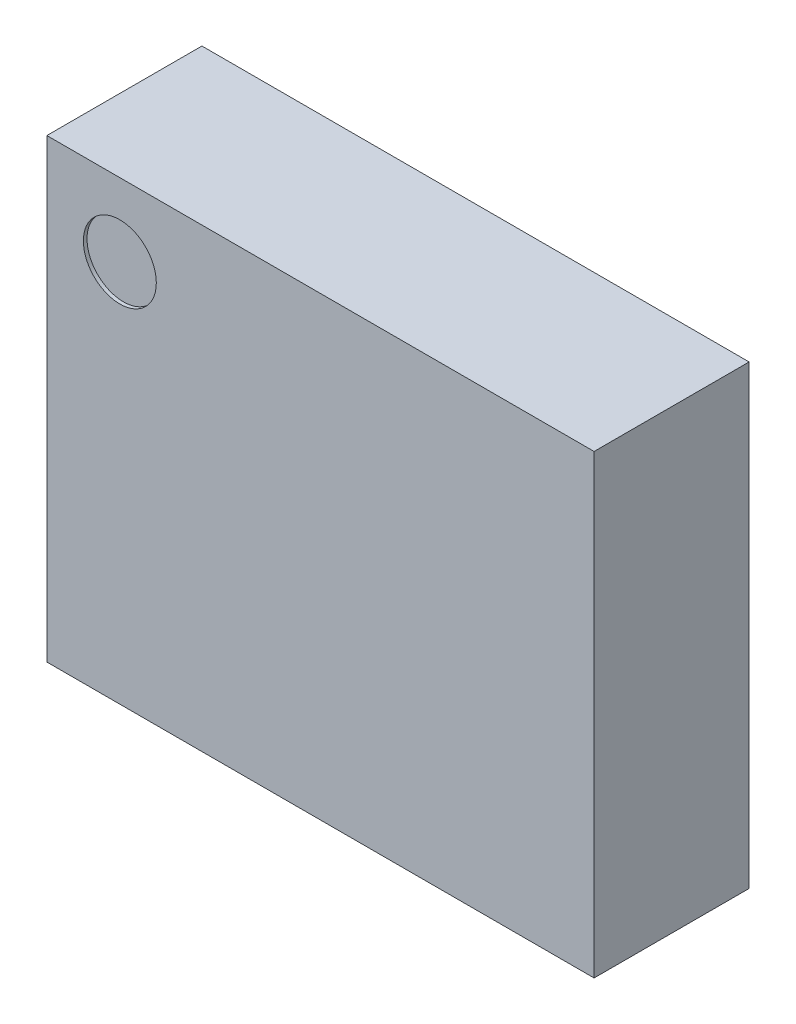
from build123d import *

# Parameters (mm, degrees)
SKETCH1_W           = 3
SKETCH1_H           = 2.5
BOSS_EXTRUDE1_DEPTH = 0.8
SKETCH2_R           = 0.2
CUT_EXTRUDE1_DEPTH  = 0.02
SKETCH3_W           = 0.25
SKETCH3_H           = 0.475
SKETCH3_W_2         = 0.475
SKETCH3_H_2         = 0.25
BOSS_EXTRUDE2_DEPTH = 0.1
SKETCH4_W           = 3
SKETCH4_H           = 2.5
BOSS_EXTRUDE3_DEPTH = 0.05


with BuildPart() as part:
    # Sketch1 → Boss-Extrude1 (new body)
    with BuildSketch(Plane.XY):
        Rectangle(SKETCH1_W, SKETCH1_H)
    extrude(amount=BOSS_EXTRUDE1_DEPTH)

    # Sketch2 → Cut-Extrude1 (cut)
    with BuildSketch(Plane.XY.offset(0.8)):
        with Locations((-1.1, 0.85)):
            Circle(SKETCH2_R)
    extrude(amount=-CUT_EXTRUDE1_DEPTH, mode=Mode.SUBTRACT)

    # Sketch3 → Boss-Extrude2 (add)
    with BuildSketch(Plane(origin=(0, 0, 0), x_dir=(-1, 0, 0), z_dir=(0, 0, -1))):
        with Locations((0.5, 0.9125)):
            Rectangle(SKETCH3_W, SKETCH3_H)
        with Locations((0, 0.9125)):
            Rectangle(SKETCH3_W, SKETCH3_H)
        with Locations((-0.5, 0.9125)):
            Rectangle(SKETCH3_W, SKETCH3_H)
        with Locations((0.5, -0.9125)):
            Rectangle(SKETCH3_W, SKETCH3_H)
        with Locations((0, -0.9125)):
            Rectangle(SKETCH3_W, SKETCH3_H)
        with Locations((-0.5, -0.9125)):
            Rectangle(SKETCH3_W, SKETCH3_H)
        with Locations((-1.1625, -0.25)):
            Rectangle(SKETCH3_W_2, SKETCH3_H_2)
        with Locations((-1.1625, 0.25)):
            Rectangle(SKETCH3_W_2, SKETCH3_H_2)
        with Locations((-1.1625, -0.75)):
            Rectangle(SKETCH3_W_2, SKETCH3_H_2)
        with Locations((-1.1625, 0.75)):
            Rectangle(SKETCH3_W_2, SKETCH3_H_2)
        with Locations((1.1625, -0.75)):
            Rectangle(SKETCH3_W_2, SKETCH3_H_2)
        with Locations((1.1625, -0.25)):
            Rectangle(SKETCH3_W_2, SKETCH3_H_2)
        with Locations((1.1625, 0.25)):
            Rectangle(SKETCH3_W_2, SKETCH3_H_2)
        with Locations((1.1625, 0.75)):
            Rectangle(SKETCH3_W_2, SKETCH3_H_2)
    extrude(amount=BOSS_EXTRUDE2_DEPTH)

    # Sketch4 → Boss-Extrude3 (add)
    with BuildSketch(Plane(origin=(0, 0, 0), x_dir=(-1, 0, 0), z_dir=(0, 0, -1))):
        Rectangle(SKETCH4_W, SKETCH4_H)
    extrude(amount=BOSS_EXTRUDE3_DEPTH)


solid = part.part
